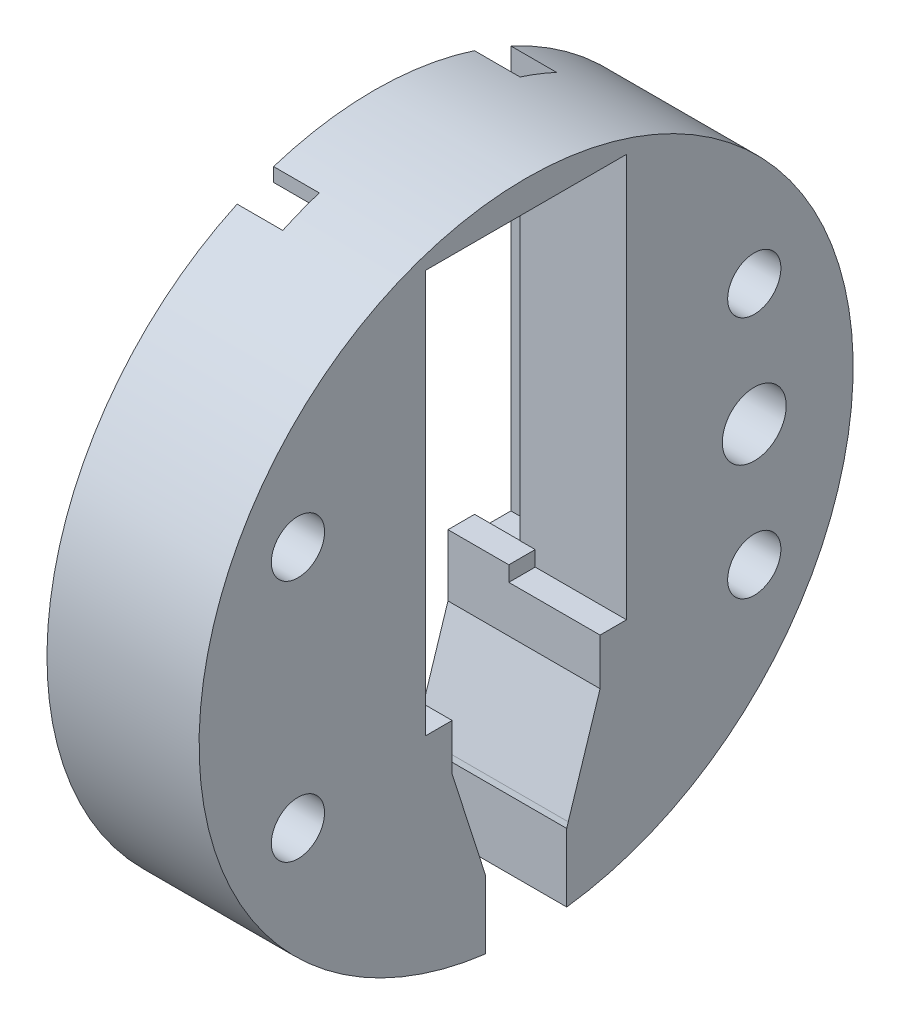
from build123d import *

# Parameters (mm, degrees)
SKETCH1_R           = 21.5
BOSS_EXTRUDE1_DEPTH = 10
CUT_EXTRUDE2_DEPTH  = 10
SKETCH15_W          = 18
SKETCH15_H          = 24.118038922
CUT_EXTRUDE3_DEPTH  = 3
SKETCH17_W          = 4
SKETCH17_H          = 1.75
BOSS_EXTRUDE3_DEPTH = 1
SKETCH18_W          = 6.5
SKETCH18_H          = 1.737607108
BOSS_EXTRUDE4_DEPTH = 1
SKETCH39_W          = 2.4
SKETCH39_H          = 4.126590585
CUT_EXTRUDE7_DEPTH  = 3
SKETCH41_R          = 1.75
SKETCH41_R_2        = 2.1
CUT_EXTRUDE8_DEPTH  = 11


with BuildPart() as part:
    # Sketch1 → Boss-Extrude1 (new body)
    with BuildSketch(Plane(origin=(0, 0, 0), x_dir=(0, 0, -1), z_dir=(1, 0, 0))):
        Circle(SKETCH1_R)
    extrude(amount=BOSS_EXTRUDE1_DEPTH)

    # Sketch13 → Cut-Extrude2 (cut)
    with BuildSketch(Plane(origin=(0, 0, 0), x_dir=(0, 0, -1), z_dir=(1, 0, 0))):
        with BuildLine():
            Line((-2.670420152, -16.85816067), (-2.770420152, -16.530371213))
            Line((-2.770420152, -16.530371213), (-4.862392892, -10))
            Line((-4.862392892, -10), (-4.862392892, -6.943148259))
            Line((-4.862392892, -6.943148259), (-6.6, -6.943148259))
            Line((-6.6, -6.943148259), (-6.6, 19.556851741))
            Line((-6.6, 19.556851741), (6.6, 19.556851741))
            Line((6.6, 19.556851741), (6.6, -6.943148259))
            Line((6.6, -6.943148259), (4.862392892, -6.943148259))
            Line((4.862392892, -6.943148259), (4.862392892, -10))
            Line((4.862392892, -10), (2.770420152, -16.530371213))
            Line((2.770420152, -16.530371213), (2.670420152, -16.85816067))
            Line((2.670420152, -16.85816067), (2.670420152, -21.837327131))
            ThreePointArc((2.670420152, -21.837327131), (1.836835043, -21.92318492), (1.000584871, -21.977234355))
            Line((1.000584871, -21.977234355), (0, -25.25))
            Line((0, -25.25), (-1.000584871, -21.977234355))
            ThreePointArc((-1.000584871, -21.977234355), (-1.836835043, -21.92318492), (-2.670420152, -21.837327131))
            Line((-2.670420152, -21.837327131), (-2.670420152, -16.85816067))
        make_face()
    extrude(amount=CUT_EXTRUDE2_DEPTH, mode=Mode.SUBTRACT)

    # Sketch15 → Cut-Extrude3 (cut)
    with BuildSketch(Plane.ZY):
        with Locations((0, 5.115871202)):
            Rectangle(SKETCH15_W, SKETCH15_H)
    extrude(amount=-CUT_EXTRUDE3_DEPTH, mode=Mode.SUBTRACT)

    # Sketch17 → Boss-Extrude3 (add)
    with BuildSketch(Plane(origin=(0, -6.943148259, 0), x_dir=(1, 0, 0), z_dir=(0, 1, 0))):
        with Locations((2, 5.737392892)):
            Rectangle(SKETCH17_W, SKETCH17_H)
    extrude(amount=BOSS_EXTRUDE3_DEPTH)

    # Sketch18 → Boss-Extrude4 (add)
    with BuildSketch(Plane(origin=(0, -6.943148259, 0), x_dir=(1, 0, 0), z_dir=(0, 1, 0))):
        with Locations((3.25, -5.731196446)):
            Rectangle(SKETCH18_W, SKETCH18_H)
    extrude(amount=BOSS_EXTRUDE4_DEPTH)

    # Sketch39 → Cut-Extrude7 (cut)
    with BuildSketch(Plane(origin=(0, 0, 0), x_dir=(0, 0, -1), z_dir=(1, 0, 0))):
        with Locations((7.8, 19.238185956)):
            Rectangle(SKETCH39_W, SKETCH39_H)
        with Locations((-7.8, 19.238185956)):
            Rectangle(SKETCH39_W, SKETCH39_H)
    extrude(amount=CUT_EXTRUDE7_DEPTH, mode=Mode.SUBTRACT)

    # Sketch41 → Cut-Extrude8 (cut, through all)
    with BuildSketch(Plane.ZY):
        with Locations((-15, 8)):
            Circle(SKETCH41_R)
        with Locations((15, 8)):
            Circle(SKETCH41_R)
        with Locations((15, -8)):
            Circle(SKETCH41_R)
        with Locations((-15, -8)):
            Circle(SKETCH41_R)
        with Locations((-15, 0)):
            Circle(SKETCH41_R_2)
    extrude(amount=-CUT_EXTRUDE8_DEPTH, mode=Mode.SUBTRACT)


solid = part.part
